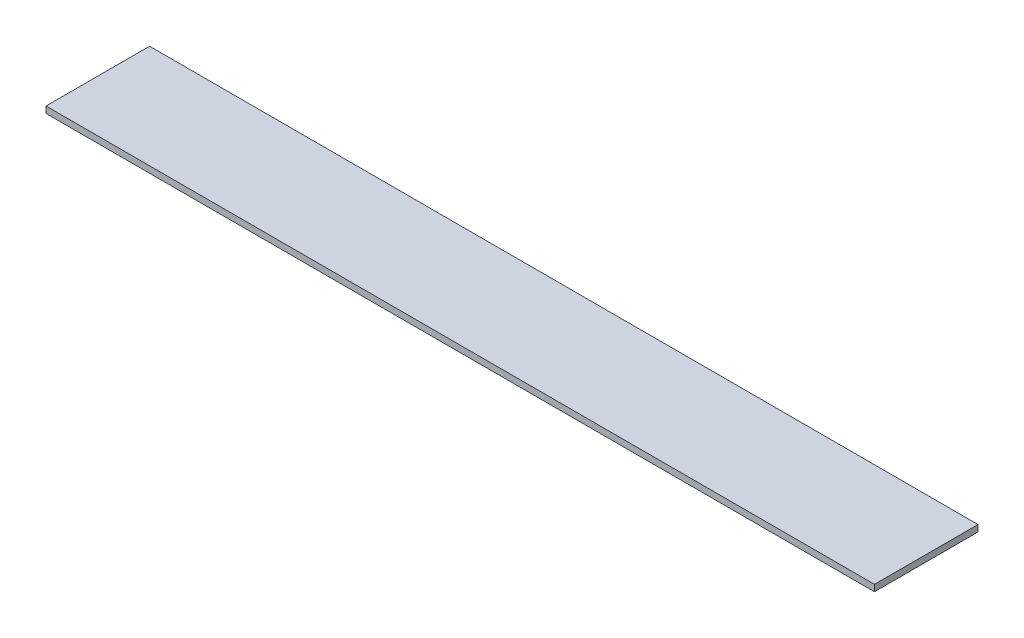
from build123d import *

# Parameters (mm, degrees)
SKETCH1_W           = 406.4
SKETCH1_H           = 50.8
BOSS_EXTRUDE1_DEPTH = 3.175


with BuildPart() as part:
    # Sketch1 → Boss-Extrude1 (new body)
    with BuildSketch(Plane(origin=(0, 0, 0), x_dir=(1, 0, 0), z_dir=(0, 1, 0))):
        with Locations((1.389067996, 54.895446614)):
            Rectangle(SKETCH1_W, SKETCH1_H)
    extrude(amount=BOSS_EXTRUDE1_DEPTH)


solid = part.part
